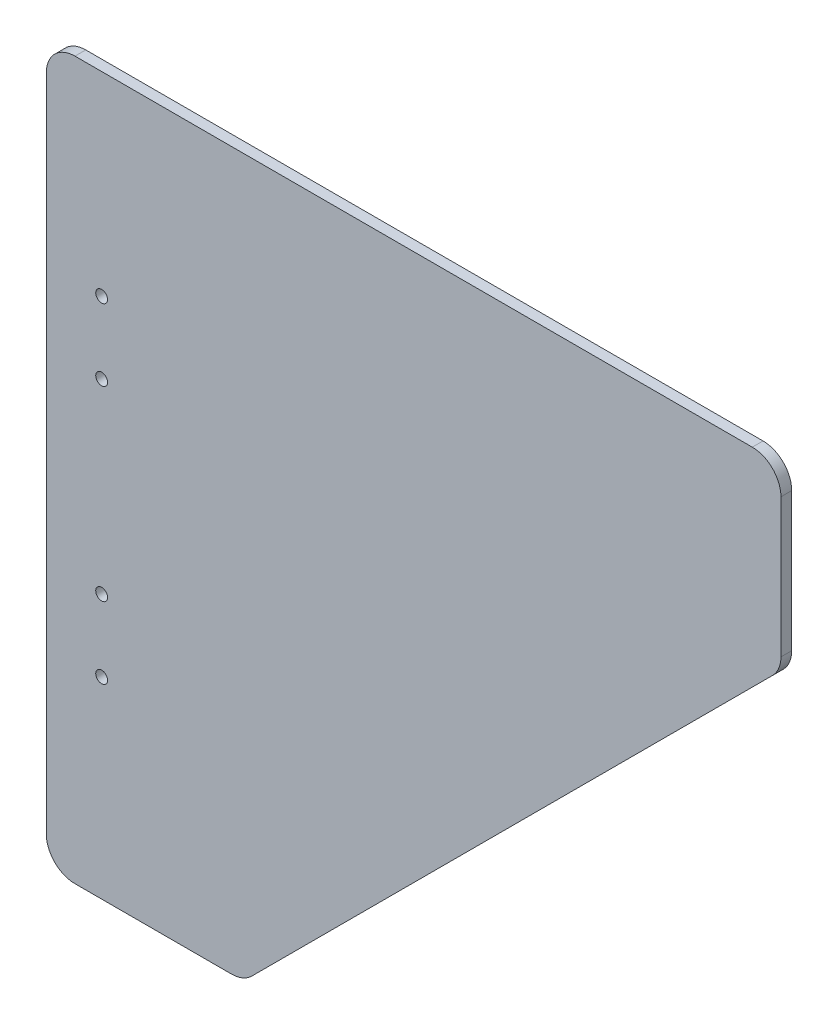
from build123d import *

# Parameters (mm, degrees)
ESTRUSIONE_ESTRUSIONE1_DEPTH    = 3
PREFORO_DA_MASCHIARE_M4_1_D     = 3.3
PREFORO_DA_MASCHIARE_M4_1_DEPTH = 40.6
PREFORO_DA_MASCHIARE_M4_1_TIP   = 0.991420021


with BuildPart() as part:
    # Schizzo1 → Estrusione-Estrusione1 (new body)
    with BuildSketch(Plane.XY):
        with BuildLine():
            Line((0, 8), (0, 192))
            ThreePointArc((0, 192), (2.343145751, 197.656854249), (8, 200))
            Line((8, 200), (197, 200))
            ThreePointArc((197, 200), (202.656854249, 197.656854249), (205, 192))
            Line((205, 192), (205, 153.313708499))
            ThreePointArc((205, 153.313708499), (204.39103626, 150.25224104), (202.656854249, 147.656854249))
            Line((202.656854249, 147.656854249), (57.343145751, 2.343145751))
            ThreePointArc((57.343145751, 2.343145751), (54.74775896, 0.60896374), (51.686291501, 0))
            Line((51.686291501, 0), (8, 0))
            ThreePointArc((8, 0), (2.343145751, 2.343145751), (0, 8))
        make_face()
    extrude(amount=ESTRUSIONE_ESTRUSIONE1_DEPTH)

    # Preforo da maschiare M4-1
    with Locations(Plane.XY.offset(3)):
        with Locations((15.44269502, 145.7), (15.44269502, 125.7), (15.44269502, 73.7), (15.44269502, 53.7)):
            Hole(PREFORO_DA_MASCHIARE_M4_1_D / 2, depth=PREFORO_DA_MASCHIARE_M4_1_DEPTH)
            with Locations((0, 0, -(PREFORO_DA_MASCHIARE_M4_1_DEPTH + PREFORO_DA_MASCHIARE_M4_1_TIP / 2))):  # 118° drill point
                Cone(0, PREFORO_DA_MASCHIARE_M4_1_D / 2, PREFORO_DA_MASCHIARE_M4_1_TIP, mode=Mode.SUBTRACT)


solid = part.part
